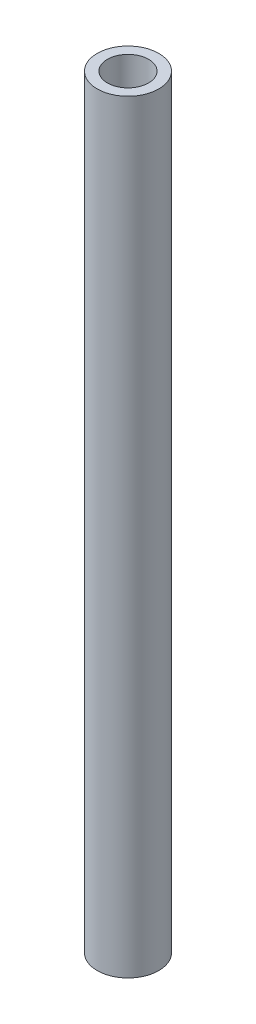
from build123d import *

# Parameters (mm, degrees)
SKETCH1_R           = 25
SKETCH1_R_2         = 16.7
BOSS_EXTRUDE1_DEPTH = 310


with BuildPart() as part:
    # Sketch1 → Boss-Extrude1 (new body, symmetric)
    with BuildSketch(Plane(origin=(0, 0, 0), x_dir=(1, 0, 0), z_dir=(0, 1, 0))):
        Circle(SKETCH1_R)
        Circle(SKETCH1_R_2, mode=Mode.SUBTRACT)
    extrude(amount=BOSS_EXTRUDE1_DEPTH, both=True)


solid = part.part
